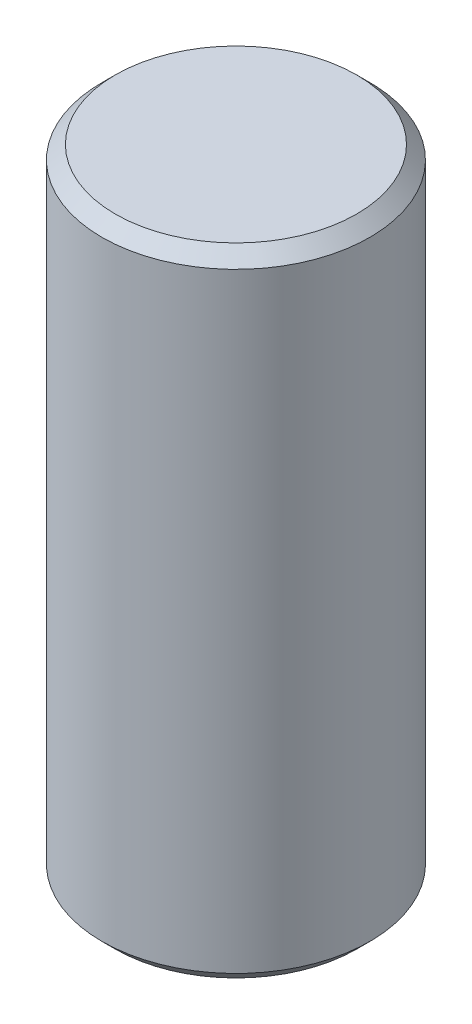
from build123d import *

# Parameters (mm, degrees)
SKETCH1_R           = 0.5
BOSS_EXTRUDE1_DEPTH = 1.1875
CHAMFER1_SIZE       = 0.05


with BuildPart() as part:
    # Sketch1 → Boss-Extrude1 (new body, symmetric)
    with BuildSketch(Plane(origin=(0, 0, 0), x_dir=(1, 0, 0), z_dir=(0, 1, 0))):
        Circle(SKETCH1_R)
    extrude(amount=BOSS_EXTRUDE1_DEPTH, both=True)

    # Chamfer1
    chamfer1_edges = [part.edges().sort_by_distance(p)[0] for p in [
        (-0.5, -1.1875, 0),
        (-0.5, 1.1875, 0),
    ]]
    chamfer(chamfer1_edges, length=CHAMFER1_SIZE)


solid = part.part
